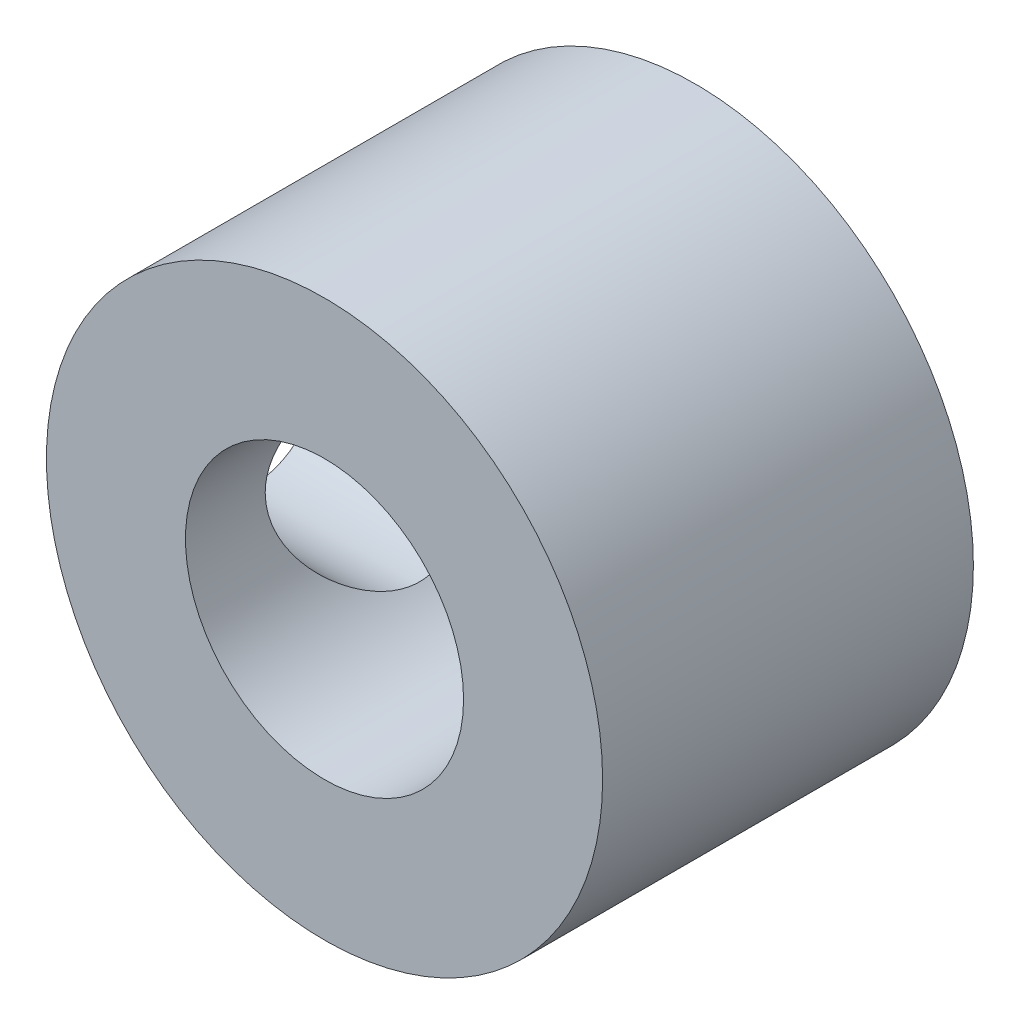
from build123d import *

# Parameters (mm, degrees)
SKETCH1_R           = 6.35
SKETCH1_R_2         = 3.175
BOSS_EXTRUDE1_DEPTH = 8.466666667
SKETCH2_R           = 2.413
CUT_EXTRUDE1_DEPTH  = 7.35


with BuildPart() as part:
    # Sketch1 → Boss-Extrude1 (new body)
    with BuildSketch(Plane.XY):
        Circle(SKETCH1_R)
        Circle(SKETCH1_R_2, mode=Mode.SUBTRACT)
    extrude(amount=BOSS_EXTRUDE1_DEPTH)

    # Sketch2 → Cut-Extrude1 (cut, through all)
    with BuildSketch(Plane(origin=(0, 0, 0), x_dir=(0, 0, -1), z_dir=(1, 0, 0))):
        with Locations((-4.233333333, 0)):
            Circle(SKETCH2_R)
    extrude(amount=-CUT_EXTRUDE1_DEPTH, mode=Mode.SUBTRACT)


solid = part.part
